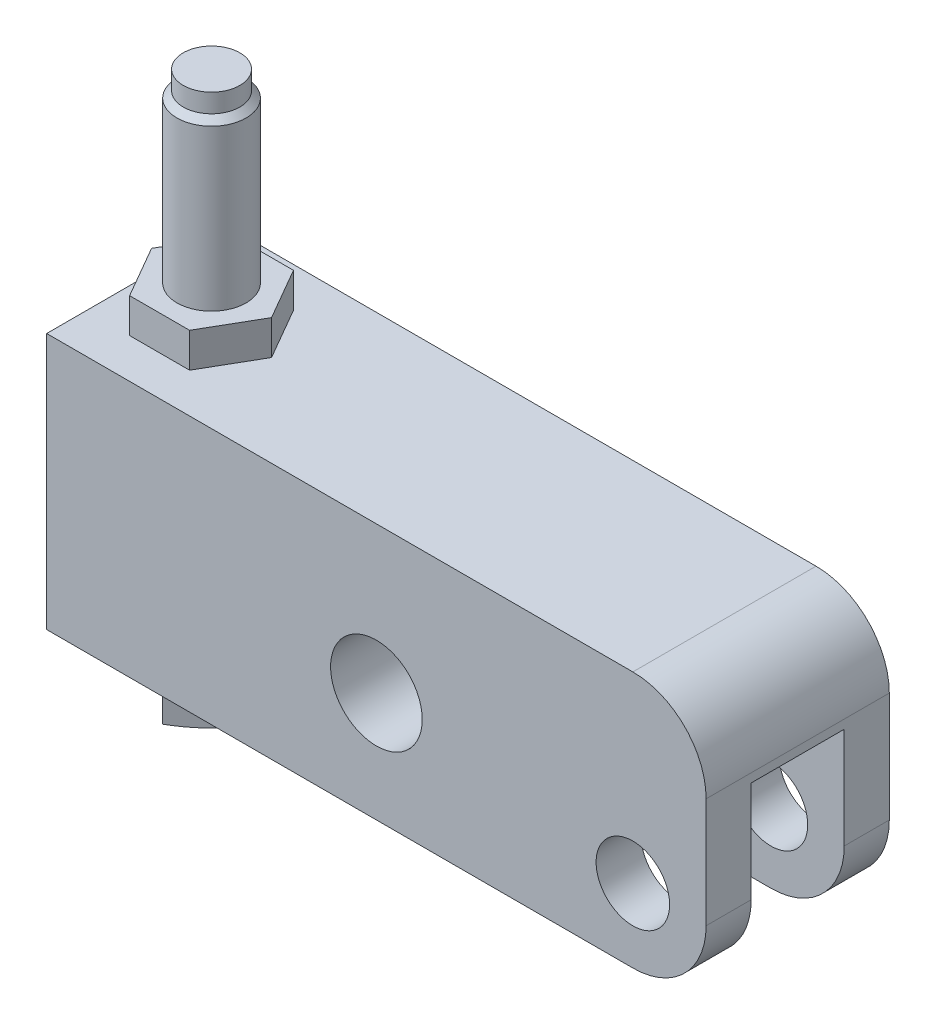
from build123d import *

# Parameters (mm, degrees)
SKETCH11_W         = 114.3
SKETCH11_H         = 44.45
SKETCH11_R         = 6.36905
SKETCH11_R_2       = 7.94385
EXTRUDE3_DEPTH     = 15.875
CUT_EXTRUDE1_DEPTH = 30.226
FILLET1_R          = 12.7
EXTRUDE4_DEPTH     = 5.9944
SKETCH15_R         = 24.22520922
CUT_EXTRUDE2_DEPTH = 12.9888


with BuildPart() as part:
    # Sketch11 → Extrude3 (new body, symmetric)
    with BuildSketch(Plane.XY):
        with Locations((-44.45, 9.525)):
            Rectangle(SKETCH11_W, SKETCH11_H)
        Circle(SKETCH11_R, mode=Mode.SUBTRACT)
        with Locations((-44.45, 6.35)):
            Circle(SKETCH11_R_2, mode=Mode.SUBTRACT)
    extrude(amount=EXTRUDE3_DEPTH, both=True)

    # Sketch12 → Cut-Extrude1 (cut)
    with BuildSketch(Plane.XZ.offset(12.7)):
        with BuildLine():
            Line((-17.526, 8.0645), (12.7, 8.0645))
            Line((12.7, 8.0645), (12.7, -8.0645))
            Line((12.7, -8.0645), (-17.526, -8.0645))
            ThreePointArc((-17.526, -8.0645), (-25.5905, 0), (-17.526, 8.0645))
        make_face()
    extrude(amount=-CUT_EXTRUDE1_DEPTH, mode=Mode.SUBTRACT)

    # Fillet1
    fillet1_edges = [part.edges().sort_by_distance(p)[0] for p in [
        (12.7, -12.7, -11.96975),
        (12.7, 31.75, 0),
        (12.7, -12.7, 11.96975),
    ]]
    fillet(fillet1_edges, radius=FILLET1_R)

    # Sketch13 → Extrude4 (add)
    with BuildSketch(Plane(origin=(0, 31.75, 0), x_dir=(1, 0, 0), z_dir=(0, 1, 0))):
        Polygon((-78.502729942, 0), (-83.701364971, 9.0043), (-94.098635029, 9.0043), (-99.297270058, 0), (-94.098635029, -9.0043), (-83.701364971, -9.0043), align=None)
    extrude(amount=EXTRUDE4_DEPTH)

    # Sketch14 → Revolve2 (revolve)
    with BuildSketch(Plane.XY, mode=Mode.PRIVATE) as revolve2_sk:
        with BuildLine():
            Line((-93.8022, 66.5988), (-93.8022, 69.85))
            Line((-93.8022, 69.85), (-88.9, 69.85))
            Line((-88.9, 69.85), (-88.9, -25.4))
            ThreePointArc((-88.9, -25.4), (-102.250110486, -22.456892404), (-113.12520922, -14.1732))
            Line((-113.12520922, -14.1732), (-113.12520922, -13.4112))
            Line((-113.12520922, -13.4112), (-94.8944, -13.4112))
            Line((-94.8944, -13.4112), (-94.8944, 65.5066))
            Line((-94.8944, 65.5066), (-93.8022, 66.5988))
        make_face()
    revolve(revolve2_sk.sketch.rotate(Axis((-88.9, 71.228986791, 0), (0, -1, 0)), 270), axis=Axis((-88.9, 71.228986791, 0), (0, -1, 0)))  # turned: the seam where the file's is

    # Sketch15 → Cut-Extrude2 (cut, through all)
    with BuildSketch(Plane(origin=(0, -13.4112, 0), x_dir=(1, 0, 0), z_dir=(0, 1, 0))):
        with Locations((-88.9, 0)):
            Circle(SKETCH15_R)
        Polygon((-88.9, 8.477361778), (-97.377361778, 0), (-88.9, -8.477361778), (-80.422638222, 0), align=None, mode=Mode.SUBTRACT)
    extrude(amount=-CUT_EXTRUDE2_DEPTH, mode=Mode.SUBTRACT)


solid = part.part
